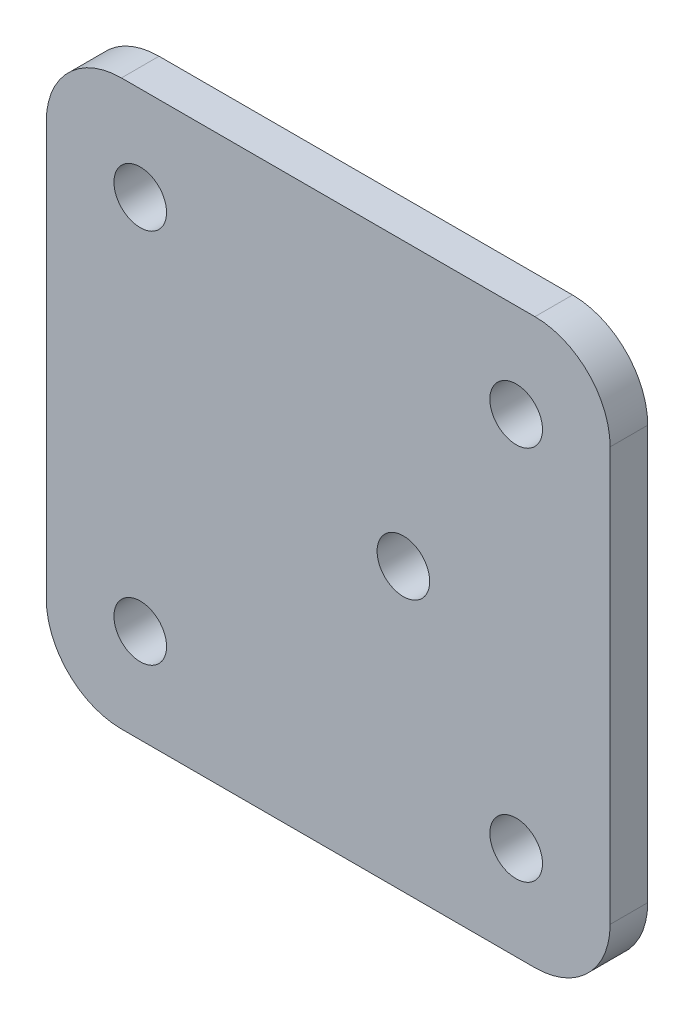
from build123d import *

# Parameters (mm, degrees)
SKETCH1_W            = 75
SKETCH1_H            = 75
BOSS_EXTRUDE1_DEPTH  = 5
M6_CLEARANCE_HOLE1_D = 7
FILLET1_R            = 10
M6_CLEARANCE_HOLE2_D = 7


with BuildPart() as part:
    # Sketch1 → Boss-Extrude1 (new body)
    with BuildSketch(Plane.XY):
        Rectangle(SKETCH1_W, SKETCH1_H)
    extrude(amount=BOSS_EXTRUDE1_DEPTH)

    # M6 Clearance Hole1 (through all)
    with Locations(Plane.XY.offset(5)):
        with Locations((-25, 25), (-25, -25), (25, -25), (25, 25)):
            Hole(M6_CLEARANCE_HOLE1_D / 2)

    # Fillet1
    fillet1_edges = [part.edges().sort_by_distance(p)[0] for p in [
        (-37.5, 37.5, 2.5),
        (37.5, 37.5, 2.5),
        (37.5, -37.5, 2.5),
        (-37.5, -37.5, 2.5),
    ]]
    fillet(fillet1_edges, radius=FILLET1_R)

    # M6 Clearance Hole2 (through all)
    with Locations(Plane.XY.offset(5)):
        with Locations((10, 0)):
            Hole(M6_CLEARANCE_HOLE2_D / 2)


solid = part.part
